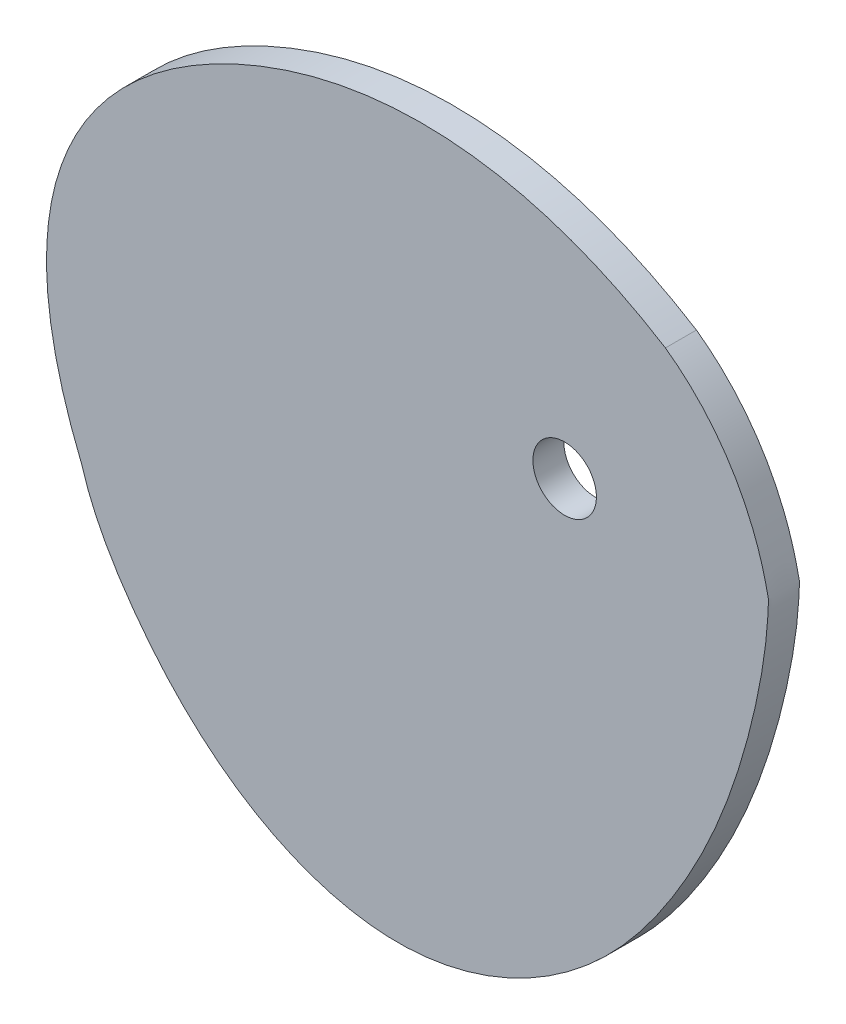
from build123d import *

# Parameters (mm, degrees)
SKETCH1_R           = 3.075
BOSS_EXTRUDE1_DEPTH = 1.5


with BuildPart() as part:
    # Sketch1 → Boss-Extrude1 (new body, symmetric)
    with BuildSketch(Plane.XY):
        with BuildLine():
            add(Edge.make_bspline(
                [(-46.720026773, -22.204755219), (-56.258450699, 0.901227349), (-32.275795778, 25.879881467), (-3.426291802, 24.043113756), (9.750652489, 15.829951888)],
                knots=[0, 0, 0, 0, 0.503099648, 0.999855604, 0.999855604, 0.999855604, 0.999855604], degree=3))
            add(Edge.make_bspline(
                [(-46.720026773, -22.204755219), (-46.680689643, -22.339756211), (-46.552337188, -22.765320129), (-46.315530335, -23.47521968), (-45.994724396, -24.328354304), (-45.64374303, -25.169381167), (-45.264635333, -25.998201376), (-44.859414404, -26.814840747), (-44.430052296, -27.619447636), (-43.978475067, -28.412290623), (-43.506557848, -29.193756113), (-43.016120213, -29.964345543), (-42.508920831, -30.724673408), (-41.98665903, -31.475455995), (-41.272178342, -32.465175872), (-40.530495583, -33.435911926), (-39.760654445, -34.385255136), (-39.168714607, -35.086236776), (-38.56223783, -35.775277911), (-37.941101655, -36.451661692), (-37.305218595, -37.114650493), (-36.654537169, -37.763487278), (-35.98904287, -38.397397013), (-35.308759098, -39.015588125), (-34.613748037, -39.617253979), (-33.904111484, -40.201574401), (-33.179991632, -40.767717226), (-32.441571792, -41.31483987), (-31.689077075, -41.842090945), (-30.922775009, -42.348611881), (-30.142976112, -42.833538592), (-29.350034402, -43.296003147), (-28.54434786, -43.735135476), (-27.72635883, -44.150065091), (-26.896554369, -44.539922823), (-26.05546653, -44.903842577), (-25.203672602, -45.240963106), (-24.34179528, -45.550429793), (-23.470502783, -45.831396446), (-22.59050891, -46.083027105), (-21.702573042, -46.304497856), (-20.807500078, -46.494998666), (-19.906140324, -46.653735147), (-18.999389287, -46.779930638), (-18.088187534, -46.872827111), (-17.173520021, -46.931690474), (-16.25641713, -46.955799458), (-15.337962254, -46.944496019), (-14.419416411, -46.897014519), (-13.502171458, -46.813870224), (-12.587669719, -46.695900505), (-11.677348446, -46.543928076), (-10.772586844, -46.358845594), (-9.874706443, -46.141589251), (-8.984969023, -45.893142696), (-8.10457535, -45.614532777), (-7.234663806, -45.306827414), (-6.376309167, -44.971132863), (-5.530521439, -44.608591087), (-4.698244808, -44.22037706), (-3.880356665, -43.807696049), (-3.07766673, -43.371780865), (-2.290916276, -42.913889097), (-1.520777431, -42.435300311), (-0.767852592, -41.937313243), (-0.032673923, -41.421242973), (0.684297044, -40.888418077), (1.38266972, -40.340177787), (2.062124662, -39.777869125), (2.722413692, -39.202844049), (3.363359912, -38.616456584), (3.984857621, -38.020059966), (4.586872142, -37.415003785), (5.16943955, -36.802631136), (5.7326663, -36.18427578), (6.276728773, -35.561259321), (6.801872699, -34.934888387), (7.308412557, -34.306451871), (7.796730652, -33.677218042), (8.267276932, -33.048432225), (8.720565676, -32.421312524), (9.157183177, -31.797052797), (9.577758987, -31.176793353), (9.983138756, -30.561603659), (10.623188649, -29.563083498), (11.342680336, -28.377433431), (12.119739062, -27.005776194), (12.731465669, -25.865724124), (13.298084183, -24.751341683), (13.822810829, -23.662816401), (14.308734968, -22.600140026), (14.82965827, -21.399879269), (15.371259255, -20.06920945), (15.976548886, -18.465026138), (16.512747902, -16.916122776), (16.988999025, -15.419907268), (17.372371177, -14.127644324), (17.68199046, -13.008697513), (17.931131914, -12.054226121), (18.129937195, -11.255668389), (18.316104219, -10.470635113), (18.49033416, -9.697832797), (18.653165351, -8.935984948), (18.804978039, -8.183844157), (18.946000172, -7.440203813), (19.076313861, -6.703909306), (19.19586254, -5.973868683), (19.304458777, -5.249062748), (19.417829782, -4.409840942), (19.500745235, -3.692433305), (19.559386299, -3.096194107), (19.591265488, -2.739927615), (19.619864108, -2.3841015), (19.645033575, -2.028659), (19.666894619, -1.673525742), (19.684543866, -1.318728399), (19.700873179, -0.9639535), (19.704615044, -0.610191975), (19.737521809, -0.250741843), (19.640954278, 0.099351506), (19.573563761, 0.452939858), (19.492985371, 0.803041009), (19.410795423, 1.15063058), (19.323979309, 1.495450325), (19.233401037, 1.837570516), (19.076564402, 2.400797966), (18.772619068, 3.395052185), (18.305566934, 4.686910126), (17.72821517, 6.038409458), (17.14129084, 7.240292034), (16.500918227, 8.398487991), (15.808316547, 9.512497778), (15.064493585, 10.581561026), (14.270307523, 11.604626241), (13.426532565, 12.580331676), (12.533925366, 13.506994912), (11.593291789, 14.38261199), (10.663595364, 15.156547445), (10.038178791, 15.624974817), (9.750652489, 15.829951888)],
                knots=[0.483675047, 0.483675047, 0.483675047, 0.483675047, 0.48572748, 0.490162693, 0.494596121, 0.499029126, 0.50346273, 0.507897674, 0.512334472, 0.516773466, 0.521214882, 0.525658883, 0.530105625, 0.534555313, 0.539008153, 0.5479229, 0.552384417, 0.556848379, 0.561314515, 0.565782528, 0.570252105, 0.57472292, 0.579194639, 0.583666924, 0.588139439, 0.592611855, 0.597083853, 0.601555132, 0.606025412, 0.610494439, 0.614961992, 0.619427887, 0.623891985, 0.628354194, 0.632814475, 0.637272853, 0.641729416, 0.646184326, 0.650637823, 0.655090233, 0.659541971, 0.663993554, 0.668445597, 0.672898832, 0.677354104, 0.681812384, 0.68627477, 0.690742499, 0.695216754, 0.699697325, 0.704183213, 0.708673274, 0.713166232, 0.71766069, 0.722155137, 0.726647962, 0.731137456, 0.735621826, 0.7400992, 0.744567632, 0.749025113, 0.753469575, 0.757898896, 0.762310907, 0.766703399, 0.771074124, 0.775420805, 0.779741136, 0.784032793, 0.788293433, 0.792520702, 0.796712241, 0.800865688, 0.804978687, 0.809048891, 0.813073968, 0.817051612, 0.820979544, 0.824855525, 0.82867736, 0.832442913, 0.836150111, 0.839796963, 0.843381676, 0.84690413, 0.857109335, 0.863622561, 0.86991433, 0.875993807, 0.881870128, 0.887552392, 0.893049665, 0.900968457, 0.908521612, 0.918075538, 0.924891611, 0.931440483, 0.937750475, 0.941838034, 0.945839551, 0.949762689, 0.953614851, 0.957403159, 0.961134423, 0.964815124, 0.96845139, 0.972048981, 0.975613274, 0.979149256, 0.984410078, 0.98615425, 0.987894493, 0.989631248, 0.991364926, 0.993095918, 0.994824589, 0.996551283, 0.998276321, 1, 1.001764203, 1.003519492, 1.005266096, 1.007004244, 1.008734164, 1.010456082, 1.01217022, 1.017268173, 1.025629542, 1.032212071, 1.038713875, 1.045147285, 1.05152405, 1.057855307, 1.064151567, 1.070422701, 1.076677929, 1.082925818, 1.089174283, 1.094328624, 1.094328624, 1.094328624, 1.094328624], degree=3))
        make_face()
        Circle(SKETCH1_R, mode=Mode.SUBTRACT)
    extrude(amount=BOSS_EXTRUDE1_DEPTH, both=True)


solid = part.part
